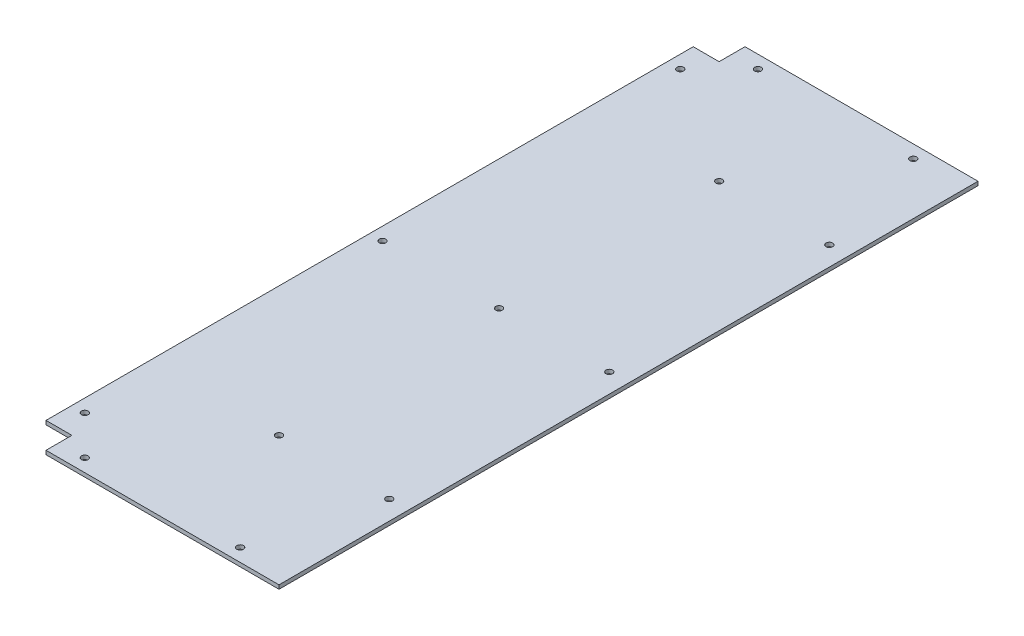
from build123d import *

# Parameters (mm, degrees)
SKETCH1_R           = 2.55
BOSS_EXTRUDE1_DEPTH = 3


with BuildPart() as part:
    # Sketch1 → Boss-Extrude1 (new body)
    with BuildSketch(Plane(origin=(0, 0, 0), x_dir=(1, 0, 0), z_dir=(0, 1, 0))):
        Polygon((-80, 270), (-80, 250), (-100, 250), (-100, -250), (-80, -250), (-80, -270), (100, -270), (100, 270), align=None)
        with Locations((-60, 260)):
            Circle(SKETCH1_R, mode=Mode.SUBTRACT)
        with Locations((60, 260)):
            Circle(SKETCH1_R, mode=Mode.SUBTRACT)
        with Locations((-90, 230)):
            Circle(SKETCH1_R, mode=Mode.SUBTRACT)
        with Locations((-90, 0)):
            Circle(SKETCH1_R, mode=Mode.SUBTRACT)
        with Locations((-90, -230)):
            Circle(SKETCH1_R, mode=Mode.SUBTRACT)
        with Locations((60, -260)):
            Circle(SKETCH1_R, mode=Mode.SUBTRACT)
        Circle(SKETCH1_R, mode=Mode.SUBTRACT)
        with Locations((0, 170)):
            Circle(SKETCH1_R, mode=Mode.SUBTRACT)
        with Locations((0, -170)):
            Circle(SKETCH1_R, mode=Mode.SUBTRACT)
        with Locations((-60, -260)):
            Circle(SKETCH1_R, mode=Mode.SUBTRACT)
        with Locations((85.164947562, 0)):
            Circle(SKETCH1_R, mode=Mode.SUBTRACT)
        with Locations((85.164947562, 170)):
            Circle(SKETCH1_R, mode=Mode.SUBTRACT)
        with Locations((85.164947562, -170)):
            Circle(SKETCH1_R, mode=Mode.SUBTRACT)
    extrude(amount=BOSS_EXTRUDE1_DEPTH)


solid = part.part
